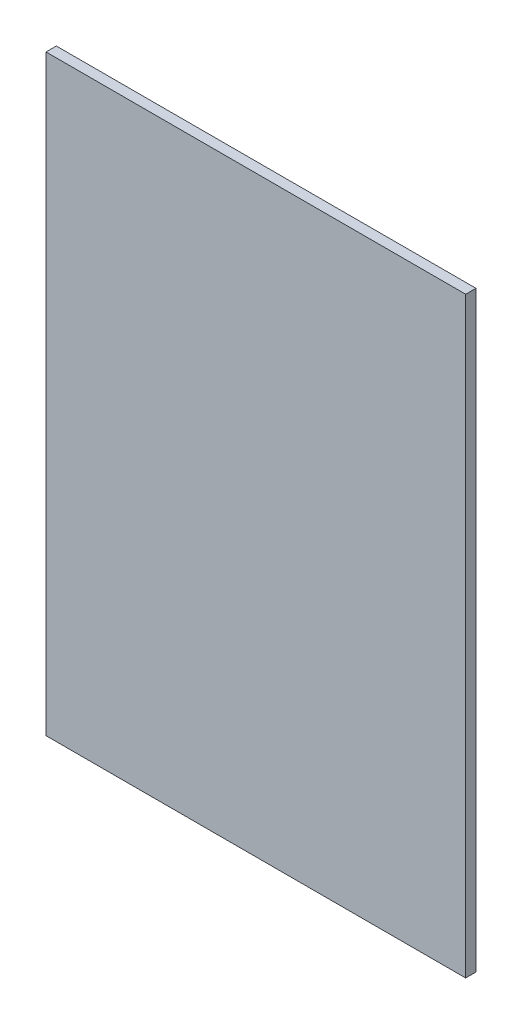
from build123d import *

# Parameters (mm, degrees)
SKETCH1_W           = 207.01
SKETCH1_H           = 292.1
BOSS_EXTRUDE1_DEPTH = 2.54


with BuildPart() as part:
    # Sketch1 → Boss-Extrude1 (new body, symmetric)
    with BuildSketch(Plane.XY):
        Rectangle(SKETCH1_W, SKETCH1_H)
    extrude(amount=BOSS_EXTRUDE1_DEPTH, both=True)


solid = part.part
